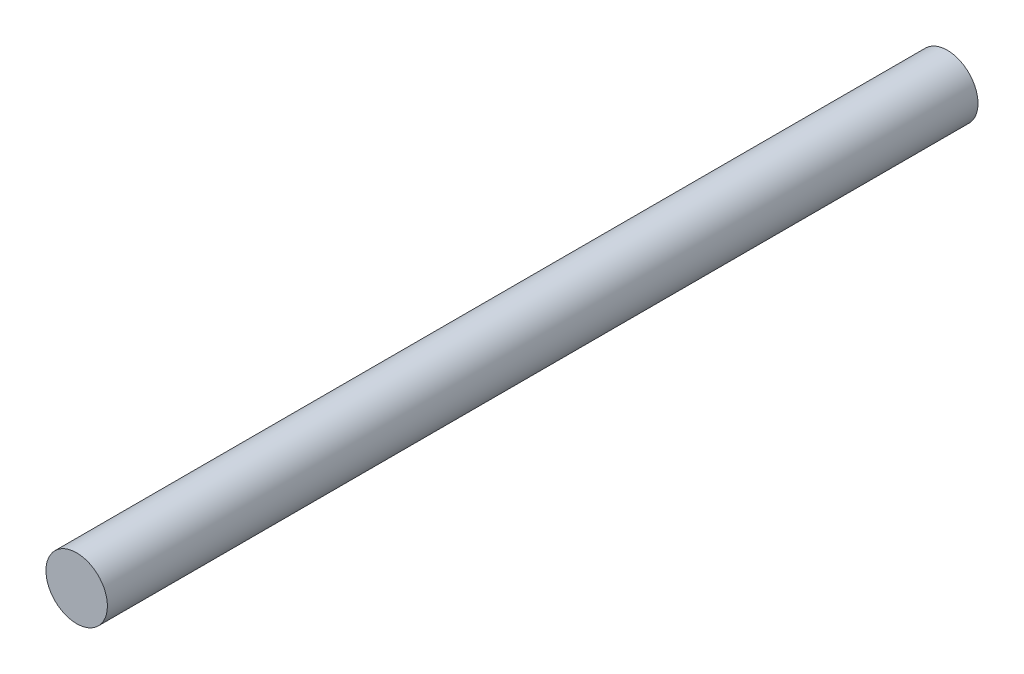
from build123d import *

# Parameters (mm, degrees)
SKETCH1_R           = 6
BOSS_EXTRUDE1_DEPTH = 85


with BuildPart() as part:
    # Sketch1 → Boss-Extrude1 (new body, symmetric)
    with BuildSketch(Plane.XY):
        Circle(SKETCH1_R)
    extrude(amount=BOSS_EXTRUDE1_DEPTH, both=True)


solid = part.part
